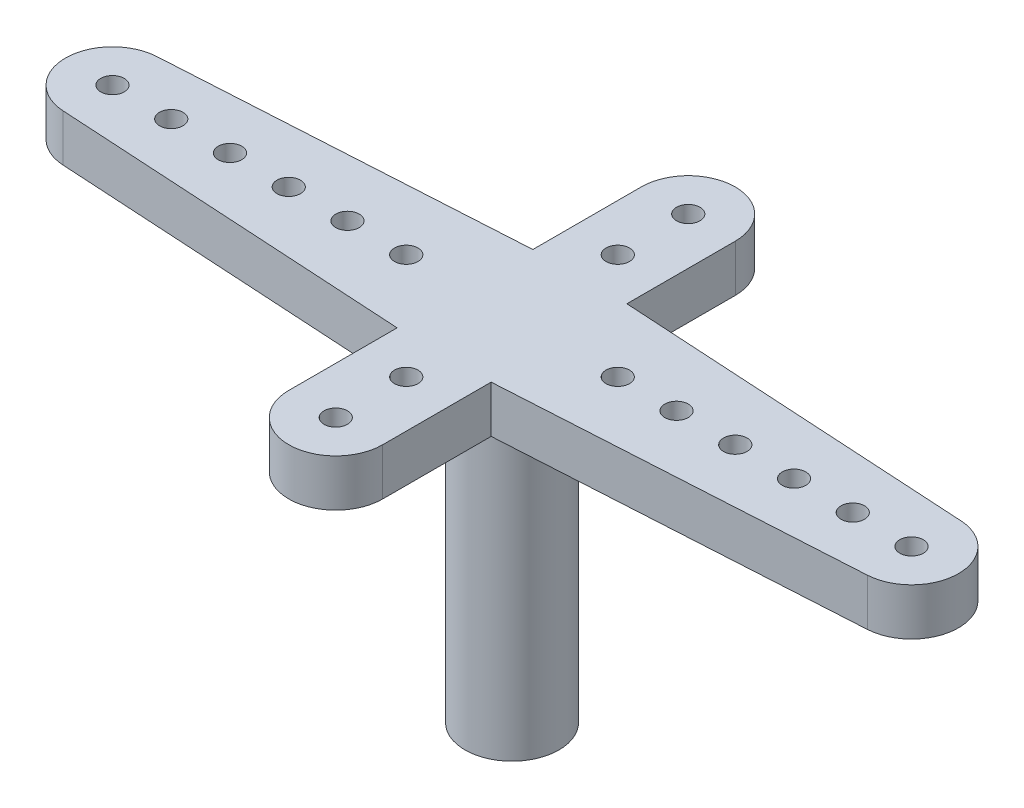
from build123d import *

# Parameters (mm, degrees)
SKETCH1_R           = 2
SKETCH1_R_2         = 0.5
BOSS_EXTRUDE1_DEPTH = 2
BOSS_EXTRUDE2_START = 2
SKETCH1_3_R         = 2
BOSS_EXTRUDE2_DEPTH = 15


with BuildPart() as part:
    # Sketch1 → Boss-Extrude1 (new body)
    with BuildSketch(Plane(origin=(0, 0, 0), x_dir=(1, 0, 0), z_dir=(0, 1, 0))):
        with BuildLine():
            Line((2, 7.5), (2, 2.88735269))
            Line((2, 2.88735269), (17.117647059, 1.996536794))
            ThreePointArc((17.117647059, 1.996536794), (19, 0), (17.117647059, -1.996536794))
            Line((17.117647059, -1.996536794), (2, -2.88735269))
            Line((2, -2.88735269), (2, -7.5))
            ThreePointArc((2, -7.5), (0, -9.5), (-2, -7.5))
            Line((-2, -7.5), (-2, -2.88735269))
            Line((-2, -2.88735269), (-17.117647059, -1.996536794))
            ThreePointArc((-17.117647059, -1.996536794), (-19, 0), (-17.117647059, 1.996536794))
            Line((-17.117647059, 1.996536794), (-2, 2.88735269))
            Line((-2, 2.88735269), (-2, 7.5))
            ThreePointArc((-2, 7.5), (0, 9.5), (2, 7.5))
        make_face()
        Circle(SKETCH1_R, mode=Mode.SUBTRACT)
        with Locations((-17, 0)):
            Circle(SKETCH1_R_2, mode=Mode.SUBTRACT)
        with Locations((17, 0)):
            Circle(SKETCH1_R_2, mode=Mode.SUBTRACT)
        with Locations((-14.5, 0)):
            Circle(SKETCH1_R_2, mode=Mode.SUBTRACT)
        with Locations((-12, 0)):
            Circle(SKETCH1_R_2, mode=Mode.SUBTRACT)
        with Locations((-9.5, 0)):
            Circle(SKETCH1_R_2, mode=Mode.SUBTRACT)
        with Locations((-7, 0)):
            Circle(SKETCH1_R_2, mode=Mode.SUBTRACT)
        with Locations((-4.5, 0)):
            Circle(SKETCH1_R_2, mode=Mode.SUBTRACT)
        with Locations((4.5, 0)):
            Circle(SKETCH1_R_2, mode=Mode.SUBTRACT)
        with Locations((7, 0)):
            Circle(SKETCH1_R_2, mode=Mode.SUBTRACT)
        with Locations((9.5, 0)):
            Circle(SKETCH1_R_2, mode=Mode.SUBTRACT)
        with Locations((12, 0)):
            Circle(SKETCH1_R_2, mode=Mode.SUBTRACT)
        with Locations((14.5, 0)):
            Circle(SKETCH1_R_2, mode=Mode.SUBTRACT)
        with Locations((0, 7.5)):
            Circle(SKETCH1_R_2, mode=Mode.SUBTRACT)
        with Locations((0, 4.5)):
            Circle(SKETCH1_R_2, mode=Mode.SUBTRACT)
        with Locations((0, -4.5)):
            Circle(SKETCH1_R_2, mode=Mode.SUBTRACT)
        with Locations((0, -7.5)):
            Circle(SKETCH1_R_2, mode=Mode.SUBTRACT)
    extrude(amount=BOSS_EXTRUDE1_DEPTH)

    # Sketch1_3 → Boss-Extrude2 (add)
    with BuildSketch(Plane(origin=(0, 0, 0), x_dir=(1, 0, 0), z_dir=(0, 1, 0)).offset(BOSS_EXTRUDE2_START)):
        Circle(SKETCH1_3_R)
    extrude(amount=-BOSS_EXTRUDE2_DEPTH)


solid = part.part
